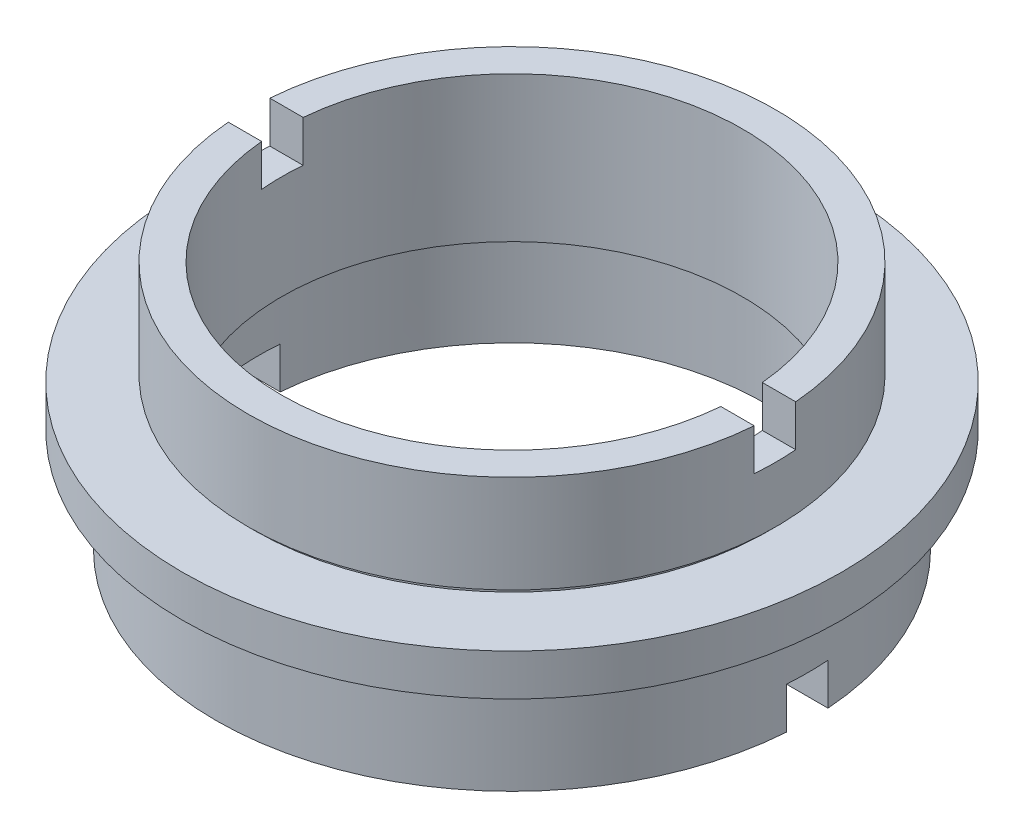
from build123d import *

# Parameters (mm, degrees)
SKETCH_2_W          = 2
SKETCH_2_H          = 3.593987872
SKETCH_2_H_2        = 6.667892238
CUT_EXTRUDE_1_DEPTH = 39.5


with BuildPart() as part:
    # 草图1 → 旋转1 (revolve)
    with BuildSketch(Plane.XY, mode=Mode.PRIVATE) as revolve_1_sk:
        Polygon((-11.1, 12), (-12.7, 12), (-12.7, 7.3), (-12.4, 7.3), (-12.4, 7), (-15.875, 7), (-15.875, 5), (-13.75, 5), (-13.75, 4), (-14.25, 4), (-14.25, 0), (-12.2, 0), (-12.2, 4.7), (-12.7, 4.7), (-12.7, 5), (-11.1, 5), align=None)
    revolve(revolve_1_sk.sketch.rotate(Axis((0, 22.677499451, 0), (0, -1, 0)), 270), axis=Axis((0, 22.677499451, 0), (0, -1, 0)))  # turned: the seam where the file's is

    # 草图2 → 切除-拉伸1 (cut, symmetric)
    with BuildSketch(Plane(origin=(0, 0, 0), x_dir=(0, 0, -1), z_dir=(1, 0, 0))):
        with Locations((0, 11.796993936)):
            Rectangle(SKETCH_2_W, SKETCH_2_H)
        with Locations((0, -1.333946119)):
            Rectangle(SKETCH_2_W, SKETCH_2_H_2)
    extrude(amount=CUT_EXTRUDE_1_DEPTH, both=True, mode=Mode.SUBTRACT)


solid = part.part
